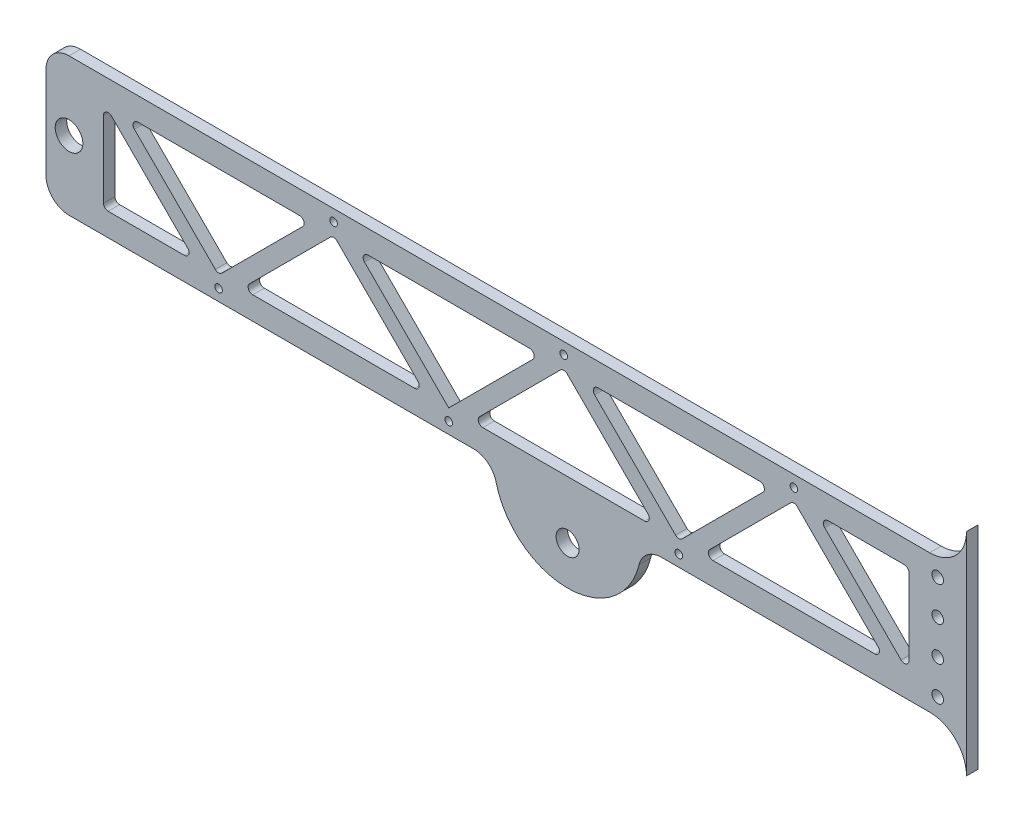
from build123d import *

# Parameters (mm, degrees)
BOSS_EXTRUDE1_DEPTH        = 5
CUT_EXTRUDE2_DEPTH         = 5
CUT_EXTRUDE3_REACH         = 7
FILLET1_R                  = 2
M6X1_0_TAPPED_HOLE1_D      = 5
M4X0_7_TAPPED_HOLE1_D      = 3.3
BOSS_EXTRUDE2_DEPTH        = 5
FILLET2_R                  = 10
F_10_0MM_DOWEL_HOLE1_D     = 10
BOSS_EXTRUDE3_DEPTH        = 5
F_12_0MM_DOWEL_HOLE1_D     = 12
F_12_0MM_DOWEL_HOLE1_DEPTH = 5


with BuildPart() as part:
    # Sketch1 → Boss-Extrude1 (new body)
    with BuildSketch(Plane.XY):
        with BuildLine():
            Line((-10, 0), (-390, 0))
            ThreePointArc((-390, 0), (-397.071067812, 2.928932188), (-400, 10))
            Line((-400, 10), (-400, 50))
            ThreePointArc((-400, 50), (-397.071067812, 57.071067812), (-390, 60))
            Line((-390, 60), (-10, 60))
            ThreePointArc((-10, 60), (-2.928932188, 57.071067812), (0, 50))
            Line((0, 50), (0, 10))
            ThreePointArc((0, 10), (-2.928932188, 2.928932188), (-10, 0))
        make_face()
    extrude(amount=BOSS_EXTRUDE1_DEPTH)

    # Sketch2 → Cut-Extrude2 (cut)
    with BuildSketch(Plane.XY.offset(5)):
        Polygon((-375, 10), (-365, 10), (-365, 40), (-375, 50), align=None)
        Polygon((-365, 40), (-365, 10), (-355, 10), (-355, 30), align=None)
        Polygon((-355, 30), (-355, 10), (-345, 10), (-345, 20), align=None)
        Polygon((-345, 20), (-345, 10), (-335, 10), align=None)
        Polygon((-305, 20), (-315, 10), (-305, 10), align=None)
        Polygon((-305, 20), (-305, 10), (-295, 10), (-295, 30), align=None)
        Polygon((-295, 30), (-295, 10), (-285, 10), (-285, 40), align=None)
        Polygon((-285, 40), (-285, 10), (-275, 10), (-275, 50), align=None)
        Polygon((-275, 50), (-275, 10), (-265, 10), (-265, 40), align=None)
        Polygon((-265, 40), (-265, 10), (-255, 10), (-255, 30), align=None)
        Polygon((-255, 30), (-255, 10), (-245, 10), (-245, 20), align=None)
        Polygon((-245, 20), (-245, 10), (-235, 10), align=None)
        Polygon((-205, 20), (-215, 10), (-205, 10), align=None)
        Polygon((-205, 20), (-205, 10), (-195, 10), (-195, 30), align=None)
        Polygon((-195, 30), (-195, 10), (-185, 10), (-185, 40), align=None)
        Polygon((-185, 40), (-185, 10), (-175, 10), (-175, 50), align=None)
        Polygon((-175, 50), (-175, 10), (-165, 10), (-165, 40), align=None)
        Polygon((-165, 40), (-165, 10), (-155, 10), (-155, 30), align=None)
        Polygon((-155, 30), (-155, 10), (-145, 10), (-145, 20), align=None)
        Polygon((-145, 20), (-145, 10), (-135, 10), align=None)
        Polygon((-45, 20), (-45, 10), (-35, 10), align=None)
        Polygon((-55, 30), (-55, 10), (-45, 10), (-45, 20), align=None)
        Polygon((-65, 40), (-65, 10), (-55, 10), (-55, 30), align=None)
        Polygon((-75, 50), (-75, 10), (-65, 10), (-65, 40), align=None)
        Polygon((-85, 40), (-85, 10), (-75, 10), (-75, 50), align=None)
        Polygon((-95, 30), (-95, 10), (-85, 10), (-85, 40), align=None)
        Polygon((-105, 20), (-105, 10), (-95, 10), (-95, 30), align=None)
        Polygon((-105, 20), (-115, 10), (-105, 10), align=None)
        Polygon((-25, 50), (-35, 50), (-35, 20), (-25, 10), align=None)
        Polygon((-35, 50), (-45, 50), (-45, 30), (-35, 20), align=None)
        Polygon((-45, 50), (-55, 50), (-55, 40), (-45, 30), align=None)
        Polygon((-55, 50), (-65, 50), (-55, 40), align=None)
    extrude(amount=-CUT_EXTRUDE2_DEPTH, mode=Mode.SUBTRACT)

    # Sketch3 → Cut-Extrude3 (cut, up to next)
    with BuildSketch(Plane.XY.offset(5), mode=Mode.PRIVATE) as cut_extrude3_sk1:
        Polygon((-365, 50), (-285, 50), (-325, 10), align=None)
    cut_extrude3_tool1 = extrude(cut_extrude3_sk1.sketch, amount=-CUT_EXTRUDE3_REACH, mode=Mode.PRIVATE) & part.part
    add(cut_extrude3_tool1.solids().sort_by_distance((-325, 36.666667, 5))[0], mode=Mode.SUBTRACT)
    # Sketch3 → Cut-Extrude3 (cut, up to next)
    with BuildSketch(Plane.XY.offset(5), mode=Mode.PRIVATE) as cut_extrude3_sk2:
        Polygon((-225, 10), (-265, 50), (-185, 50), align=None)
    cut_extrude3_tool2 = extrude(cut_extrude3_sk2.sketch, amount=-CUT_EXTRUDE3_REACH, mode=Mode.PRIVATE) & part.part
    add(cut_extrude3_tool2.solids().sort_by_distance((-225, 36.666667, 5))[0], mode=Mode.SUBTRACT)
    # Sketch3 → Cut-Extrude3 (cut, up to next)
    with BuildSketch(Plane.XY.offset(5), mode=Mode.PRIVATE) as cut_extrude3_sk3:
        Polygon((-125, 10), (-165, 50), (-85, 50), align=None)
    cut_extrude3_tool3 = extrude(cut_extrude3_sk3.sketch, amount=-CUT_EXTRUDE3_REACH, mode=Mode.PRIVATE) & part.part
    add(cut_extrude3_tool3.solids().sort_by_distance((-125, 36.666667, 5))[0], mode=Mode.SUBTRACT)

    # Fillet1
    fillet1_edges = [part.edges().sort_by_distance(p)[0] for p in [
        (-325, 10, 2.5),
        (-365, 50, 2.5),
        (-285, 50, 2.5),
        (-265, 50, 2.5),
        (-185, 50, 2.5),
        (-165, 50, 2.5),
        (-85, 50, 2.5),
        (-125, 10, 2.5),
        (-375, 50, 2.5),
        (-335, 10, 2.5),
        (-375, 10, 2.5),
        (-315, 10, 2.5),
        (-275, 50, 2.5),
        (-235, 10, 2.5),
        (-215, 10, 2.5),
        (-175, 50, 2.5),
        (-135, 10, 2.5),
        (-65, 50, 2.5),
        (-25, 50, 2.5),
        (-25, 10, 2.5),
        (-75, 50, 2.5),
        (-35, 10, 2.5),
        (-115, 10, 2.5),
    ]]
    fillet(fillet1_edges, radius=FILLET1_R)

    # M6x1.0 Tapped Hole1 (through all)
    with Locations(Plane.XY.offset(5)):
        with Locations((-12.5, 52.5), (-12.5, 37.5), (-12.5, 22.5), (-12.5, 7.5)):
            Hole(M6X1_0_TAPPED_HOLE1_D / 2)

    # M4x0.7 Tapped Hole1 (through all)
    with Locations(Plane.XY.offset(5)):
        with Locations((-225, 5), (-175, 55), (-125, 5), (-75, 55), (-275, 55), (-325, 5)):
            Hole(M4X0_7_TAPPED_HOLE1_D / 2)

    # Sketch9 → Boss-Extrude2 (add)
    with BuildSketch(Plane.XY.offset(5)):
        with BuildLine():
            Line((-205.342623586, 0), (-141.342623586, 0))
            ThreePointArc((-141.342623586, 0), (-173.342623586, -32), (-205.342623586, 0))
        make_face()
    extrude(amount=-BOSS_EXTRUDE2_DEPTH)

    # Fillet2
    fillet2_edges = [part.edges().sort_by_distance(p)[0] for p in [
        (-205.342623586, 0, 2.5),
        (-141.342623586, 0, 2.5),
    ]]
    fillet(fillet2_edges, radius=FILLET2_R)

    # Ø10.0mm Dowel Hole1 (through all)
    with Locations(Plane.XY.offset(5)):
        with Locations((-173.342623586, -15)):
            Hole(F_10_0MM_DOWEL_HOLE1_D / 2)

    # Sketch12 → Boss-Extrude3 (add)
    with BuildSketch(Plane.XY.offset(5)):
        with BuildLine():
            Line((0, 76), (0, 50))
            ThreePointArc((0, 50), (-6.566018868, 57.294369811), (-16, 60))
            ThreePointArc((-16, 60), (-4.686291501, 64.686291501), (0, 76))
        make_face()
        with BuildLine():
            Line((0, 10), (0, -16))
            ThreePointArc((0, -16), (-4.686291501, -4.686291501), (-16, 0))
            ThreePointArc((-16, 0), (-6.566018868, 2.705630189), (0, 10))
        make_face()
    extrude(amount=-BOSS_EXTRUDE3_DEPTH)

    # Ø12.0mm Dowel Hole1
    with Locations(Plane.XY.offset(5)):
        with Locations((-390, 30)):
            Hole(F_12_0MM_DOWEL_HOLE1_D / 2, depth=F_12_0MM_DOWEL_HOLE1_DEPTH)


solid = part.part
